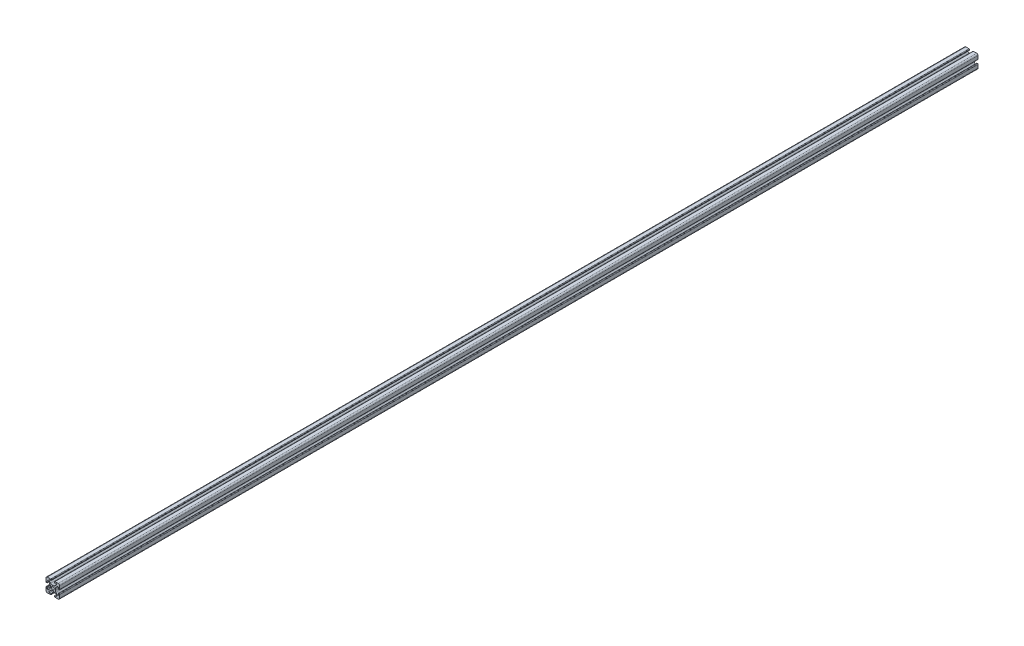
from build123d import *

# Parameters (mm, degrees)
SKETCH3_R                = 2.15
BOSS_EXTRUDE1_DEPTH      = 675
BOSS_EXTRUDE1_DEPTH_BACK = 675


with BuildPart() as part:
    # Sketch3 → Boss-Extrude1 (new body, two sides)
    with BuildSketch(Plane.XY) as boss_extrude1_sk:
        with BuildLine():
            Line((3.2874, 10), (8, 10))
            ThreePointArc((8, 10), (9.414213562, 9.414213562), (10, 8))
            Line((10, 8), (10, 3.2874))
            ThreePointArc((10, 3.2874), (9.76937588, 2.73062412), (9.2126, 2.5))
            Line((9.2126, 2.5), (8.5048, 2.5))
            ThreePointArc((8.5048, 2.5), (8.289273853, 2.589273853), (8.2, 2.8048))
            Line((8.2, 2.8048), (8.2, 4.9118))
            ThreePointArc((8.2, 4.9118), (7.682565253, 5.686195824), (6.769103096, 5.504496904))
            Line((6.769103096, 5.504496904), (4.478679656, 3.214073464))
            ThreePointArc((4.478679656, 3.214073464), (3.828361402, 2.240803418), (3.6, 1.092753121))
            Line((3.6, 1.092753121), (3.6, -1.092753121))
            ThreePointArc((3.6, -1.092753121), (3.828361402, -2.240803418), (4.478679656, -3.214073464))
            Line((4.478679656, -3.214073464), (6.769103096, -5.504496904))
            ThreePointArc((6.769103096, -5.504496904), (7.682565253, -5.686195824), (8.2, -4.9118))
            Line((8.2, -4.9118), (8.2, -2.8048))
            ThreePointArc((8.2, -2.8048), (8.289273853, -2.589273853), (8.5048, -2.5))
            Line((8.5048, -2.5), (9.2126, -2.5))
            ThreePointArc((9.2126, -2.5), (9.76937588, -2.73062412), (10, -3.2874))
            Line((10, -3.2874), (10, -8))
            ThreePointArc((10, -8), (9.414213562, -9.414213562), (8, -10))
            Line((8, -10), (3.2874, -10))
            ThreePointArc((3.2874, -10), (2.73062412, -9.76937588), (2.5, -9.2126))
            Line((2.5, -9.2126), (2.5, -8.5048))
            ThreePointArc((2.5, -8.5048), (2.589273853, -8.289273853), (2.8048, -8.2))
            Line((2.8048, -8.2), (4.9118, -8.2))
            ThreePointArc((4.9118, -8.2), (5.686195824, -7.682565253), (5.504496904, -6.769103096))
            Line((5.504496904, -6.769103096), (3.214073464, -4.478679656))
            ThreePointArc((3.214073464, -4.478679656), (2.240803418, -3.828361402), (1.092753121, -3.6))
            Line((1.092753121, -3.6), (-1.092753121, -3.6))
            ThreePointArc((-1.092753121, -3.6), (-2.240803418, -3.828361402), (-3.214073464, -4.478679656))
            Line((-3.214073464, -4.478679656), (-5.504496904, -6.769103096))
            ThreePointArc((-5.504496904, -6.769103096), (-5.686195824, -7.682565253), (-4.9118, -8.2))
            Line((-4.9118, -8.2), (-2.8048, -8.2))
            ThreePointArc((-2.8048, -8.2), (-2.589273853, -8.289273853), (-2.5, -8.5048))
            Line((-2.5, -8.5048), (-2.5, -9.2126))
            ThreePointArc((-2.5, -9.2126), (-2.73062412, -9.76937588), (-3.2874, -10))
            Line((-3.2874, -10), (-8, -10))
            ThreePointArc((-8, -10), (-9.414213562, -9.414213562), (-10, -8))
            Line((-10, -8), (-10, -3.2874))
            ThreePointArc((-10, -3.2874), (-9.76937588, -2.73062412), (-9.2126, -2.5))
            Line((-9.2126, -2.5), (-8.5048, -2.5))
            ThreePointArc((-8.5048, -2.5), (-8.289273853, -2.589273853), (-8.2, -2.8048))
            Line((-8.2, -2.8048), (-8.2, -4.9118))
            ThreePointArc((-8.2, -4.9118), (-7.682565253, -5.686195824), (-6.769103096, -5.504496904))
            Line((-6.769103096, -5.504496904), (-4.478679656, -3.214073464))
            ThreePointArc((-4.478679656, -3.214073464), (-3.828361402, -2.240803418), (-3.6, -1.092753121))
            Line((-3.6, -1.092753121), (-3.6, 1.092753121))
            ThreePointArc((-3.6, 1.092753121), (-3.828361402, 2.240803418), (-4.478679656, 3.214073464))
            Line((-4.478679656, 3.214073464), (-6.769103096, 5.504496904))
            ThreePointArc((-6.769103096, 5.504496904), (-7.682565253, 5.686195824), (-8.2, 4.9118))
            Line((-8.2, 4.9118), (-8.2, 2.8048))
            ThreePointArc((-8.2, 2.8048), (-8.289273853, 2.589273853), (-8.5048, 2.5))
            Line((-8.5048, 2.5), (-9.2126, 2.5))
            ThreePointArc((-9.2126, 2.5), (-9.76937588, 2.73062412), (-10, 3.2874))
            Line((-10, 3.2874), (-10, 8))
            ThreePointArc((-10, 8), (-9.414213562, 9.414213562), (-8, 10))
            Line((-8, 10), (-3.2874, 10))
            ThreePointArc((-3.2874, 10), (-2.73062412, 9.76937588), (-2.5, 9.2126))
            Line((-2.5, 9.2126), (-2.5, 8.5048))
            ThreePointArc((-2.5, 8.5048), (-2.589273853, 8.289273853), (-2.8048, 8.2))
            Line((-2.8048, 8.2), (-4.9118, 8.2))
            ThreePointArc((-4.9118, 8.2), (-5.686195824, 7.682565253), (-5.504496904, 6.769103096))
            Line((-5.504496904, 6.769103096), (-3.214073464, 4.478679656))
            ThreePointArc((-3.214073464, 4.478679656), (-2.240803418, 3.828361402), (-1.092753121, 3.6))
            Line((-1.092753121, 3.6), (1.092753121, 3.6))
            ThreePointArc((1.092753121, 3.6), (2.240803418, 3.828361402), (3.214073464, 4.478679656))
            Line((3.214073464, 4.478679656), (5.504496904, 6.769103096))
            ThreePointArc((5.504496904, 6.769103096), (5.686195824, 7.682565253), (4.9118, 8.2))
            Line((4.9118, 8.2), (2.8048, 8.2))
            ThreePointArc((2.8048, 8.2), (2.589273853, 8.289273853), (2.5, 8.5048))
            Line((2.5, 8.5048), (2.5, 9.2126))
            ThreePointArc((2.5, 9.2126), (2.73062412, 9.76937588), (3.2874, 10))
        make_face()
        Circle(SKETCH3_R, mode=Mode.SUBTRACT)
    extrude(amount=BOSS_EXTRUDE1_DEPTH)
    extrude(boss_extrude1_sk.sketch, amount=-BOSS_EXTRUDE1_DEPTH_BACK)


solid = part.part
